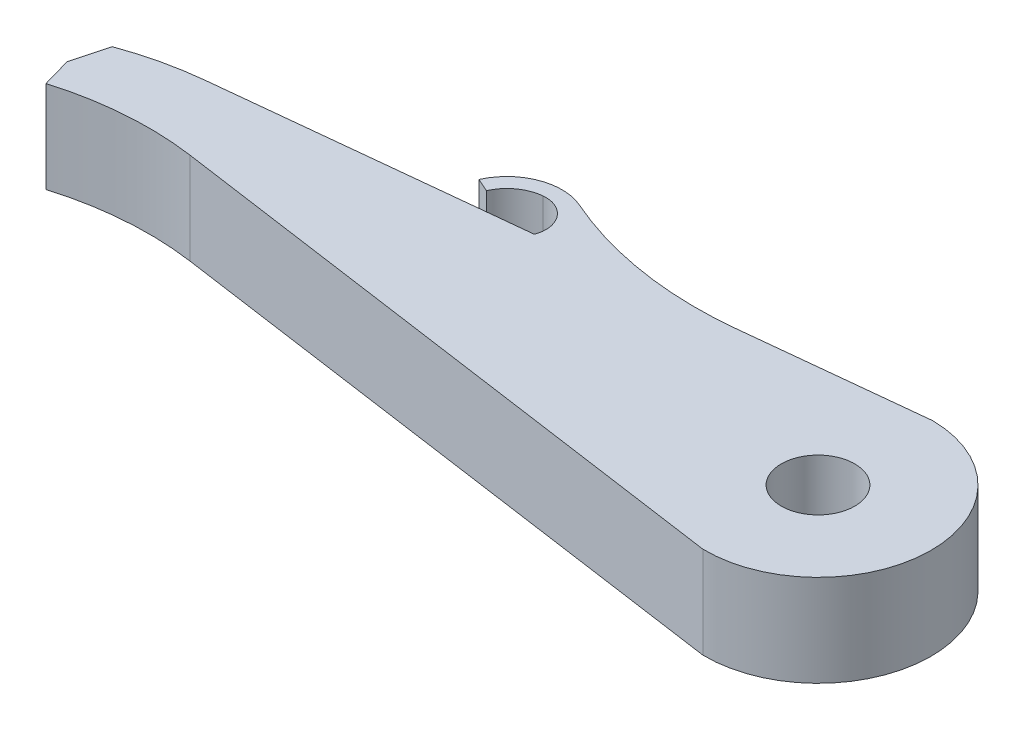
from build123d import *

# Parameters (mm, degrees)
SKETCH_2_R          = 1
EXTRUDE_1_DEPTH     = 2.5
CUT_EXTRUDE_1_DEPTH = 10
FILLET_1_R          = 10


with BuildPart() as part:
    # 草图2 → 凸台-拉伸1 (new body)
    with BuildSketch(Plane(origin=(0, 0, 0), x_dir=(1, 0, 0), z_dir=(0, 1, 0))):
        with BuildLine():
            Line((14.476416474, 15.856761921), (14.874238191, 15.898449826))
            ThreePointArc((14.874238191, 15.898449826), (13.617518302, 17.223579787), (12.012278006, 16.352650461))
            Line((12.012278006, 16.352650461), (12.377645672, 16.189842387))
            ThreePointArc((12.377645672, 16.189842387), (12.736119234, 16.632239525), (13.267765014, 16.836129905))
            ThreePointArc((13.267765014, 16.836129905), (14.074924495, 16.596765827), (14.476416474, 15.856761921))
        make_face()
        with BuildLine():
            ThreePointArc((13.267765014, 16.836129905), (13.948344657, 16.54497389), (14.058411092, 15.812958962))
            Line((14.058411092, 15.812958962), (14.476416474, 15.856761921))
            ThreePointArc((14.476416474, 15.856761921), (14.074924495, 16.596765827), (13.267765014, 16.836129905))
        make_face()
        with BuildLine():
            Line((8.01763809, 14.922232709), (7.5, 12.990381057))
            Line((7.5, 12.990381057), (23.780514318, 10.680802356))
            ThreePointArc((23.780514318, 10.680802356), (26.918139154, 13.705908304), (23.893033206, 16.84353314))
            Line((23.893033206, 16.84353314), (14.874238191, 15.898449826))
            Line((14.874238191, 15.898449826), (14.476416474, 15.856761921))
            Line((14.476416474, 15.856761921), (14.058411092, 15.812958962))
            Line((14.058411092, 15.812958962), (5.923249556, 14.96047197))
            ThreePointArc((5.923249556, 14.96047197), (6.971617953, 15.005660189), (8.01763809, 14.922232709))
        make_face()
        with Locations((23.836773762, 13.762167748)):
            Circle(SKETCH_2_R, mode=Mode.SUBTRACT)
        with BuildLine():
            ThreePointArc((3.882285677, 14.488887394), (5.923249556, 14.96047197), (8.01763809, 14.922232709))
            Line((8.01763809, 14.922232709), (7.5, 12.990381057))
            ThreePointArc((7.5, 12.990381057), (5.405611466, 13.028620317), (3.364647586, 12.557035742))
            Line((3.364647586, 12.557035742), (3.882285677, 14.488887394))
        make_face()
    extrude(amount=EXTRUDE_1_DEPTH)

    # 草图3 → 切除-拉伸1 (cut)
    with BuildSketch(Plane(origin=(0, 2.5, 0), x_dir=(1, 0, 0), z_dir=(0, 1, 0))):
        Polygon((3.623466631, 13.522961568), (3.851948064, 12.718387546), (3.364647586, 12.557035742), align=None)
    extrude(amount=-CUT_EXTRUDE_1_DEPTH, mode=Mode.SUBTRACT)

    # 圆角1
    fillet_1_edges = [part.edges().sort_by_distance(p)[0] for p in [
        (14.874238191, 1.25, -15.898449826),
    ]]
    fillet(fillet_1_edges, radius=FILLET_1_R)


solid = part.part
